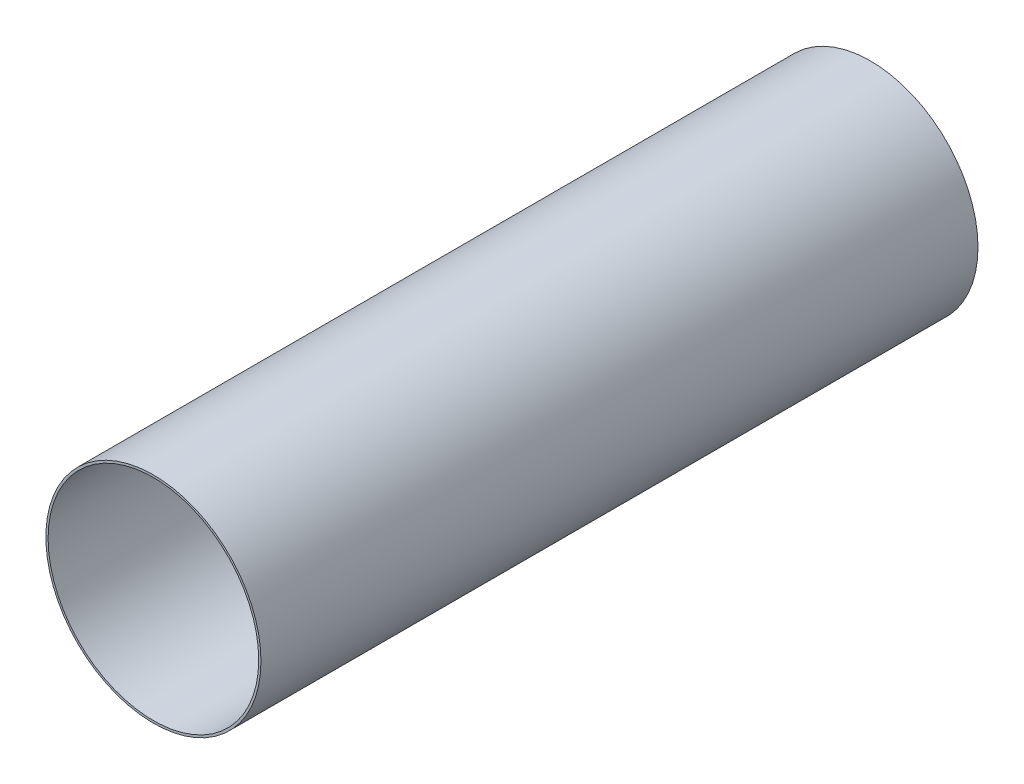
from build123d import *

# Parameters (mm, degrees)
SKETCH1_R           = 152.4
BOSS_EXTRUDE1_DEPTH = 1016
SKETCH2_R           = 149.225
CUT_EXTRUDE1_DEPTH  = 1016


with BuildPart() as part:
    # Sketch1 → Boss-Extrude1 (new body)
    with BuildSketch(Plane.XY):
        Circle(SKETCH1_R)
    extrude(amount=BOSS_EXTRUDE1_DEPTH)

    # Sketch2 → Cut-Extrude1 (cut)
    with BuildSketch(Plane.XY.offset(1016)):
        Circle(SKETCH2_R)
    extrude(amount=-CUT_EXTRUDE1_DEPTH, mode=Mode.SUBTRACT)


solid = part.part
